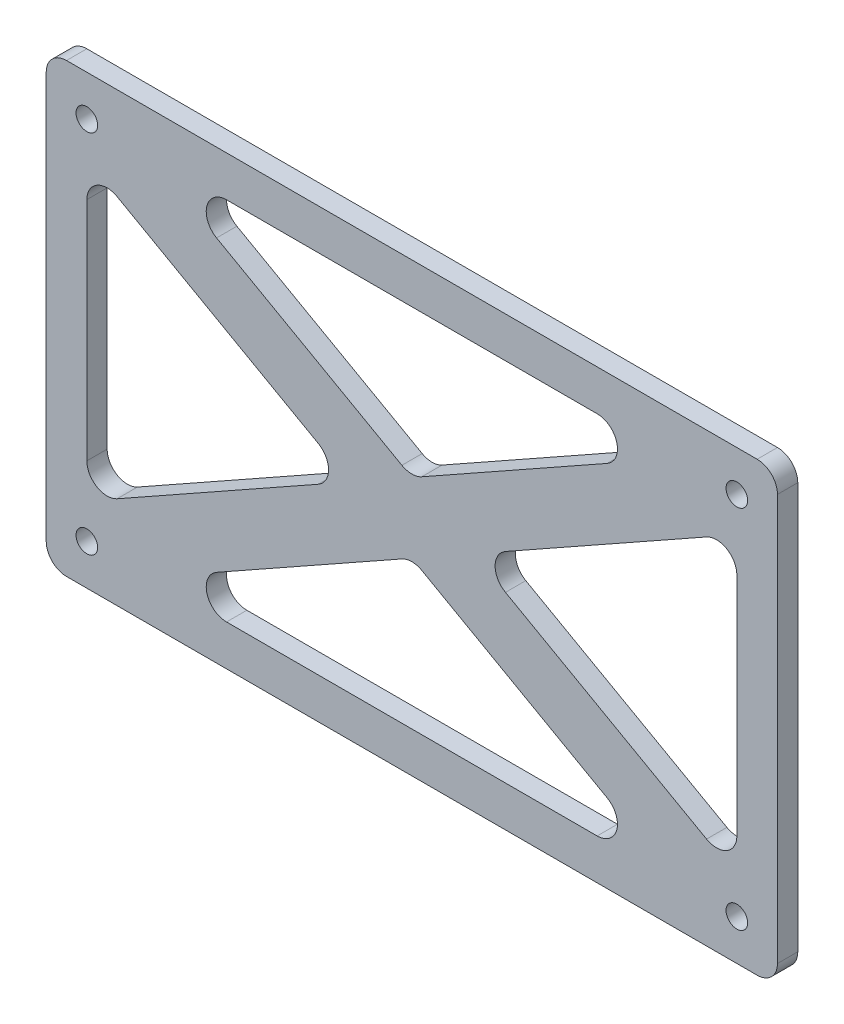
from build123d import *

# Parameters (mm, degrees)
SKETCH1_W                   = 228.6
SKETCH1_H                   = 139.7
SKETCH1_W_2                 = 203.2
SKETCH1_H_2                 = 114.3
BOSS_EXTRUDE1_DEPTH         = 6.35
BOSS_EXTRUDE2_DEPTH         = 6.35
FILLET1_R                   = 6.35
FILLET2_R                   = 6.35
F_1_4_CLEARANCE_HOLE1_D     = 6.7564
F_1_4_CLEARANCE_HOLE1_DEPTH = 9.906
F_1_4_CLEARANCE_HOLE1_TIP   = 2.029827343


with BuildPart() as part:
    # Sketch1 → Boss-Extrude1 (new body)
    with BuildSketch(Plane.XY):
        Rectangle(SKETCH1_W, SKETCH1_H)
        Rectangle(SKETCH1_W_2, SKETCH1_H_2, mode=Mode.SUBTRACT)
    extrude(amount=BOSS_EXTRUDE1_DEPTH)

    # Sketch2 → Boss-Extrude2 (add)
    with BuildSketch(Plane.XY.offset(6.35)):
        with BuildLine():
            Line((-96.930261692, 65.451756991), (0, 10.928484789))
            Line((0, 10.928484789), (96.930261692, 65.451756991))
            ThreePointArc((96.930261692, 65.451756991), (109.901756991, 61.819738308), (106.269738308, 48.848243009))
            Line((106.269738308, 48.848243009), (19.428417403, 0))
            Line((19.428417403, 0), (106.269738308, -48.848243009))
            ThreePointArc((106.269738308, -48.848243009), (109.901756991, -61.819738308), (96.930261692, -65.451756991))
            Line((96.930261692, -65.451756991), (0, -10.928484789))
            Line((0, -10.928484789), (-96.930261692, -65.451756991))
            ThreePointArc((-96.930261692, -65.451756991), (-109.901756991, -61.819738308), (-106.269738308, -48.848243009))
            Line((-106.269738308, -48.848243009), (-19.428417403, 0))
            Line((-19.428417403, 0), (-106.269738308, 48.848243009))
            ThreePointArc((-106.269738308, 48.848243009), (-109.901756991, 61.819738308), (-96.930261692, 65.451756991))
        make_face()
    extrude(amount=-BOSS_EXTRUDE2_DEPTH)

    # Fillet1
    fillet1_edges = [part.edges().sort_by_distance(p)[0] for p in [
        (82.171582597, 57.15, 3.175),
        (-82.171582597, 57.15, 3.175),
        (101.6, -46.221515211, 3.175),
        (101.6, 46.221515211, 3.175),
        (-82.171582597, -57.15, 3.175),
        (82.171582597, -57.15, 3.175),
        (-101.6, 46.221515211, 3.175),
        (-101.6, -46.221515211, 3.175),
        (0, 10.928484789, 3.175),
        (19.428417403, 0, 3.175),
        (0, -10.928484789, 3.175),
        (-19.428417403, 0, 3.175),
    ]]
    fillet(fillet1_edges, radius=FILLET1_R)

    # Fillet2
    fillet2_edges = [part.edges().sort_by_distance(p)[0] for p in [
        (114.3, -69.85, 3.175),
        (-114.3, -69.85, 3.175),
        (-114.3, 69.85, 3.175),
        (114.3, 69.85, 3.175),
    ]]
    fillet(fillet2_edges, radius=FILLET2_R)

    # 1/4 Clearance Hole1
    with Locations(Plane.XY.offset(6.35)):
        with Locations((-101.6, 57.15), (101.6, 57.15), (-101.6, -57.15), (101.6, -57.15)):
            Hole(F_1_4_CLEARANCE_HOLE1_D / 2, depth=F_1_4_CLEARANCE_HOLE1_DEPTH)
            with Locations((0, 0, -(F_1_4_CLEARANCE_HOLE1_DEPTH + F_1_4_CLEARANCE_HOLE1_TIP / 2))):  # 118° drill point
                Cone(0, F_1_4_CLEARANCE_HOLE1_D / 2, F_1_4_CLEARANCE_HOLE1_TIP, mode=Mode.SUBTRACT)


solid = part.part
